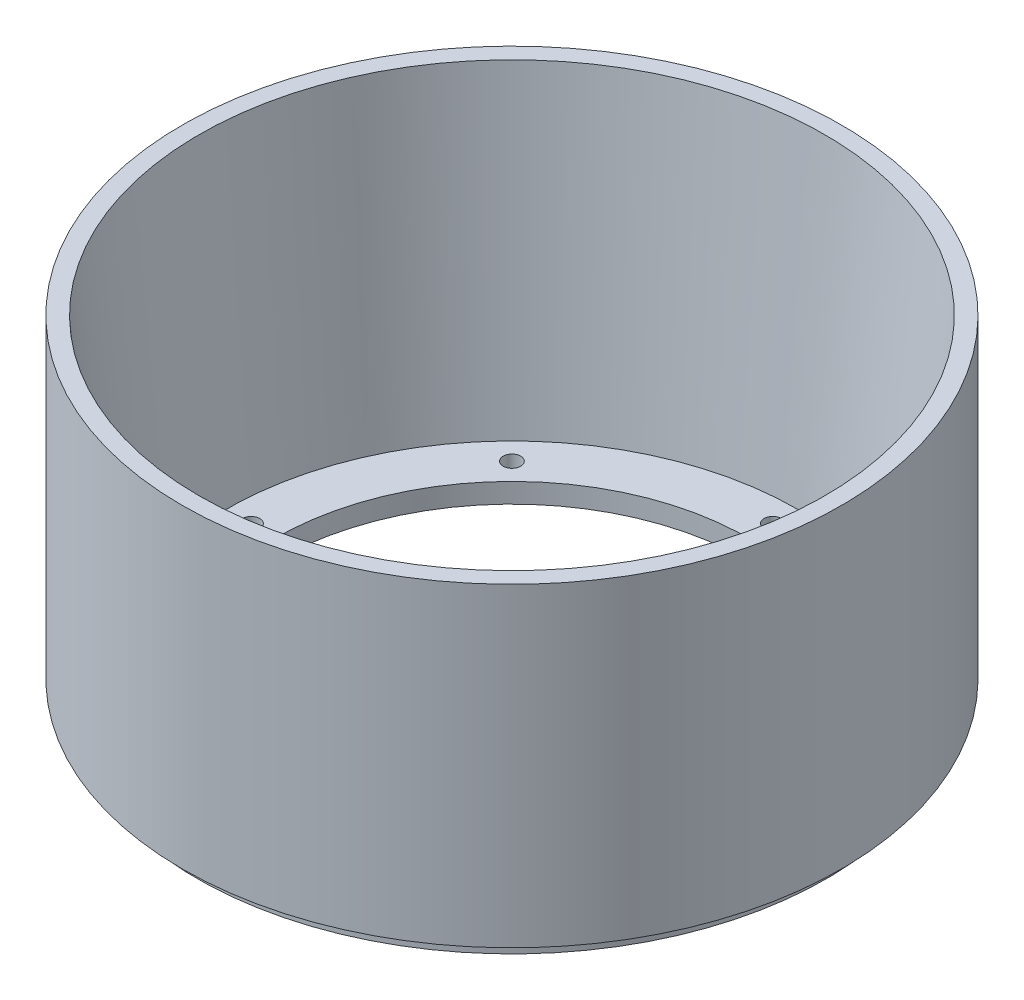
from build123d import *

# Parameters (mm, degrees)
SKETCH1_R           = 53.18125
BOSS_EXTRUDE1_DEPTH = 50.8
SKETCH2_R           = 50.8
SKETCH2_R_2         = 50.4825
BOSS_EXTRUDE2_DEPTH = 2.54
SKETCH3_R           = 50.4825
CUT_EXTRUDE1_DEPTH  = 50.165
CUT_EXTRUDE1_DRAFT  = -5
SKETCH4_R           = 38.1
CUT_EXTRUDE3_DEPTH  = 3.175
SKETCH5_R           = 1.41224
CUT_EXTRUDE4_DEPTH  = 91.404745053
CIRPATTERN4_COUNT   = 8


with BuildPart() as part:
    # Sketch1 → Boss-Extrude1 (new body)
    with BuildSketch(Plane(origin=(0, 0, 0), x_dir=(1, 0, 0), z_dir=(0, 1, 0))):
        with Locations(Location((0, 0, 0), (0, 0, 270))):
            Circle(SKETCH1_R)
    extrude(amount=BOSS_EXTRUDE1_DEPTH)

    # Sketch2 → Boss-Extrude2 (add)
    with BuildSketch(Plane.XZ):
        with Locations(Location((0, 0, 0), (0, 0, 270))):
            Circle(SKETCH2_R)
        Circle(SKETCH2_R_2, mode=Mode.SUBTRACT)
        Circle(SKETCH2_R_2)
    extrude(amount=BOSS_EXTRUDE2_DEPTH)


with BuildPart() as cut_extrude1_tool:
    # Sketch3 → Cut-Extrude1 (with draft: the straight prism first)
    with BuildSketch(Plane(origin=(0, 50.8, 0), x_dir=(1, 0, 0), z_dir=(0, 1, 0))):
        Circle(SKETCH3_R)
    extrude(amount=-CUT_EXTRUDE1_DEPTH)
    # Cut-Extrude1: the draft: its side faces are tilted about the plane it starts from
    cut_extrude1_sides = [cut_extrude1_tool.faces().sort_by_distance(p)[0] for p in [
        (-50.4825, 25.7175, 0),
    ]]
    draft(cut_extrude1_sides, Plane(origin=(0, 50.8, 0), x_dir=(1, 0, 0), z_dir=(0, 1, 0)), CUT_EXTRUDE1_DRAFT)


with BuildPart() as part_1:
    add(part.part)

    # Cut-Extrude1: cut by cut_extrude1_tool
    add(cut_extrude1_tool.part, mode=Mode.SUBTRACT)

    # Sketch4 → Cut-Extrude3 (cut)
    with BuildSketch(Plane(origin=(0, 0.635, 0), x_dir=(1, 0, 0), z_dir=(0, 1, 0))):
        with Locations(Location((0, 0, 0), (0, 0, 270))):
            Circle(SKETCH4_R)
    extrude(amount=-CUT_EXTRUDE3_DEPTH, mode=Mode.SUBTRACT)

    # Sketch5 → Cut-Extrude4 (cut, through all)
    with BuildSketch(Plane(origin=(0, 0.635, 0), x_dir=(1, 0, 0), z_dir=(0, 1, 0))):
        with Locations(Location((-42.096815597, 0, 0), (0, 0, 270))):
            Circle(SKETCH5_R)
    cut_extrude4 = extrude(amount=-CUT_EXTRUDE4_DEPTH, mode=Mode.SUBTRACT)

    # CirPattern4: Cut-Extrude4 ×8 about axis
    cirpattern4_axis = Axis((0, 0, 0), (0, 1, 0))
    for i in range(1, CIRPATTERN4_COUNT):
        add(cut_extrude4.rotate(cirpattern4_axis, i * 360 / CIRPATTERN4_COUNT), mode=Mode.SUBTRACT)


solid = part_1.part
